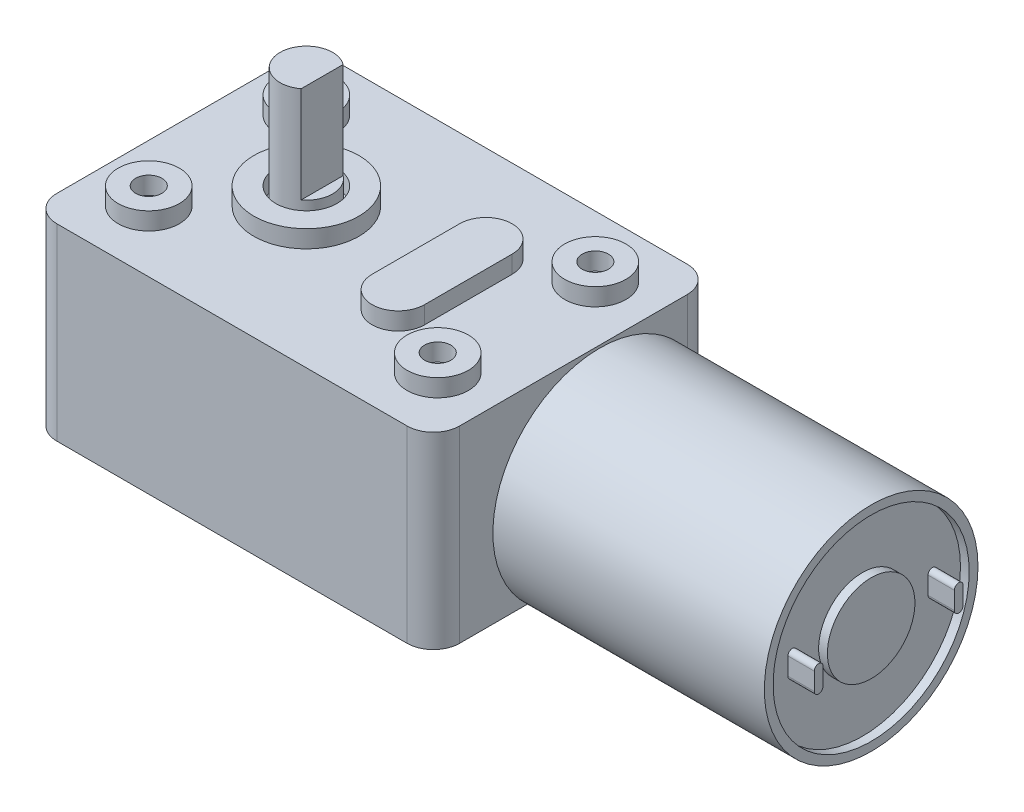
from build123d import *

# Parameters (mm, degrees)
SKETCH1_W           = 46
SKETCH1_H           = 32
BOSS_EXTRUDE1_DEPTH = 21.5
FILLET1_R           = 3
SKETCH2_R           = 3.5
SKETCH2_R_2         = 1.5
SKETCH2_R_3         = 6
BOSS_EXTRUDE2_DEPTH = 2
SKETCH3_R           = 3
BOSS_EXTRUDE3_DEPTH = 13.7
CUT_EXTRUDE1_START  = -11
CUT_EXTRUDE1_DEPTH  = 11
BOSS_EXTRUDE4_START = 2
SKETCH5_R           = 6
SKETCH5_R_2         = 3.5
SKETCH5_R_3         = 1.5
BOSS_EXTRUDE4_DEPTH = 2
SKETCH6_R           = 12.2
BOSS_EXTRUDE5_DEPTH = 31
SKETCH7_R           = 11.2
SKETCH7_R_2         = 5
CUT_EXTRUDE2_DEPTH  = 1
BOSS_EXTRUDE6_DEPTH = 3
CIRPATTERN1_COUNT   = 2


with BuildPart() as part:
    # Sketch1 → Boss-Extrude1 (new body)
    with BuildSketch(Plane(origin=(0, 0, 0), x_dir=(1, 0, 0), z_dir=(0, 1, 0))):
        Rectangle(SKETCH1_W, SKETCH1_H)
    extrude(amount=BOSS_EXTRUDE1_DEPTH)

    # Fillet1
    fillet1_edges = [part.edges().sort_by_distance(p)[0] for p in [
        (-23, 10.75, -16),
        (23, 10.75, -16),
        (23, 10.75, 16),
        (-23, 10.75, 16),
    ]]
    fillet(fillet1_edges, radius=FILLET1_R)

    # Sketch2 → Boss-Extrude2 (add)
    # profile 1 of 6: a face of its own
    with BuildSketch(Plane(origin=(0, 21.5, 0), x_dir=(1, 0, 0), z_dir=(0, 1, 0))):
        with Locations((-16.5, 9)):
            Circle(SKETCH2_R)
        with Locations((-16.5, 9)):
            Circle(SKETCH2_R_2, mode=Mode.SUBTRACT)
    # profile 2 of 6: a face of its own
    with BuildSketch(Plane(origin=(0, 21.5, 0), x_dir=(1, 0, 0), z_dir=(0, 1, 0))):
        with Locations((16.5, 9)):
            Circle(SKETCH2_R)
        with Locations((16.5, 9)):
            Circle(SKETCH2_R_2, mode=Mode.SUBTRACT)
    # profile 3 of 6: a face of its own
    with BuildSketch(Plane(origin=(0, 21.5, 0), x_dir=(1, 0, 0), z_dir=(0, 1, 0))):
        with Locations((16.5, -9)):
            Circle(SKETCH2_R)
        with Locations((16.5, -9)):
            Circle(SKETCH2_R_2, mode=Mode.SUBTRACT)
    # profile 4 of 6: a face of its own
    with BuildSketch(Plane(origin=(0, 21.5, 0), x_dir=(1, 0, 0), z_dir=(0, 1, 0))):
        with Locations((-16.5, -9)):
            Circle(SKETCH2_R)
        with Locations((-16.5, -9)):
            Circle(SKETCH2_R_2, mode=Mode.SUBTRACT)
    # profile 5 of 6: a face of its own
    with BuildSketch(Plane(origin=(0, 21.5, 0), x_dir=(1, 0, 0), z_dir=(0, 1, 0))):
        with Locations((-7.5, 0)):
            Circle(SKETCH2_R_3)
        with Locations((-7.5, 0)):
            Circle(SKETCH2_R, mode=Mode.SUBTRACT)
    # profile 6 of 6: a face of its own
    with BuildSketch(Plane(origin=(0, 21.5, 0), x_dir=(1, 0, 0), z_dir=(0, 1, 0))):
        with BuildLine():
            Line((11, 5), (11, -5))
            ThreePointArc((11, -5), (8, -8), (5, -5))
            Line((5, -5), (5, 5))
            ThreePointArc((5, 5), (8, 8), (11, 5))
        make_face()
    extrude(amount=BOSS_EXTRUDE2_DEPTH)

    # Sketch3 → Boss-Extrude3 (add)
    with BuildSketch(Plane(origin=(0, 21.5, 0), x_dir=(1, 0, 0), z_dir=(0, 1, 0))):
        with Locations((-7.5, 0)):
            Circle(SKETCH3_R)
    extrude(amount=BOSS_EXTRUDE3_DEPTH)

    # Sketch4 → Cut-Extrude1 (cut)
    with BuildSketch(Plane(origin=(0, 35.2, 0), x_dir=(1, 0, 0), z_dir=(0, 1, 0)).offset(CUT_EXTRUDE1_START)):
        with BuildLine():
            ThreePointArc((-4.5, 0), (-4.816718427, 1.341640786), (-5.7, 2.4))
            Line((-5.7, 2.4), (-5.7, -2.4))
            ThreePointArc((-5.7, -2.4), (-4.816718427, -1.341640786), (-4.5, 0))
        make_face()
    extrude(amount=CUT_EXTRUDE1_DEPTH, mode=Mode.SUBTRACT)

    # Sketch5 → Boss-Extrude4 (add)
    # profile 1 of 6: a face of its own
    with BuildSketch(Plane.XZ.offset(BOSS_EXTRUDE4_START)):
        with Locations((-7.5, 0)):
            Circle(SKETCH5_R)
    # profile 2 of 6: a face of its own
    with BuildSketch(Plane.XZ.offset(BOSS_EXTRUDE4_START)):
        with Locations((-16.5, -9)):
            Circle(SKETCH5_R_2)
        with Locations((-16.5, -9)):
            Circle(SKETCH5_R_3, mode=Mode.SUBTRACT)
    # profile 3 of 6: a face of its own
    with BuildSketch(Plane.XZ.offset(BOSS_EXTRUDE4_START)):
        with Locations((-16.5, 9)):
            Circle(SKETCH5_R_2)
        with Locations((-16.5, 9)):
            Circle(SKETCH5_R_3, mode=Mode.SUBTRACT)
    # profile 4 of 6: a face of its own
    with BuildSketch(Plane.XZ.offset(BOSS_EXTRUDE4_START)):
        with Locations((16.5, 9)):
            Circle(SKETCH5_R_2)
        with Locations((16.5, 9)):
            Circle(SKETCH5_R_3, mode=Mode.SUBTRACT)
    # profile 5 of 6: a face of its own
    with BuildSketch(Plane.XZ.offset(BOSS_EXTRUDE4_START)):
        with Locations((16.5, -9)):
            Circle(SKETCH5_R_2)
        with Locations((16.5, -9)):
            Circle(SKETCH5_R_3, mode=Mode.SUBTRACT)
    # profile 6 of 6: a face of its own
    with BuildSketch(Plane.XZ.offset(BOSS_EXTRUDE4_START)):
        with BuildLine():
            Line((11, -5), (11, 5))
            ThreePointArc((11, 5), (8, 8), (5, 5))
            Line((5, 5), (5, -5))
            ThreePointArc((5, -5), (8, -8), (11, -5))
        make_face()
    extrude(amount=-BOSS_EXTRUDE4_DEPTH)

    # Sketch6 → Boss-Extrude5 (add)
    with BuildSketch(Plane(origin=(23, 0, 0), x_dir=(0, 0, -1), z_dir=(1, 0, 0))):
        with Locations((3, 9)):
            Circle(SKETCH6_R)
    extrude(amount=BOSS_EXTRUDE5_DEPTH)

    # Sketch7 → Cut-Extrude2 (cut)
    with BuildSketch(Plane(origin=(54, 0, 0), x_dir=(0, 0, -1), z_dir=(1, 0, 0))):
        with Locations((3, 9)):
            Circle(SKETCH7_R)
        with Locations((3, 9)):
            Circle(SKETCH7_R_2, mode=Mode.SUBTRACT)
    extrude(amount=-CUT_EXTRUDE2_DEPTH, mode=Mode.SUBTRACT)

    # Sketch8 → Boss-Extrude6 (add)
    with BuildSketch(Plane(origin=(53, 0, 0), x_dir=(0, 0, -1), z_dir=(1, 0, 0))):
        with BuildLine():
            Line((-5.5, 8), (-5.5, 10))
            ThreePointArc((-5.5, 10), (-5, 10.5), (-4.5, 10))
            Line((-4.5, 10), (-4.5, 8))
            ThreePointArc((-4.5, 8), (-5, 7.5), (-5.5, 8))
        make_face()
    boss_extrude6 = extrude(amount=BOSS_EXTRUDE6_DEPTH)

    # CirPattern1: Boss-Extrude6 ×2 about axis
    cirpattern1_axis = Axis((54, 9, -3), (1, 0, 0))
    for i in range(1, CIRPATTERN1_COUNT):
        add(boss_extrude6.rotate(cirpattern1_axis, i * 360 / CIRPATTERN1_COUNT))


solid = part.part
